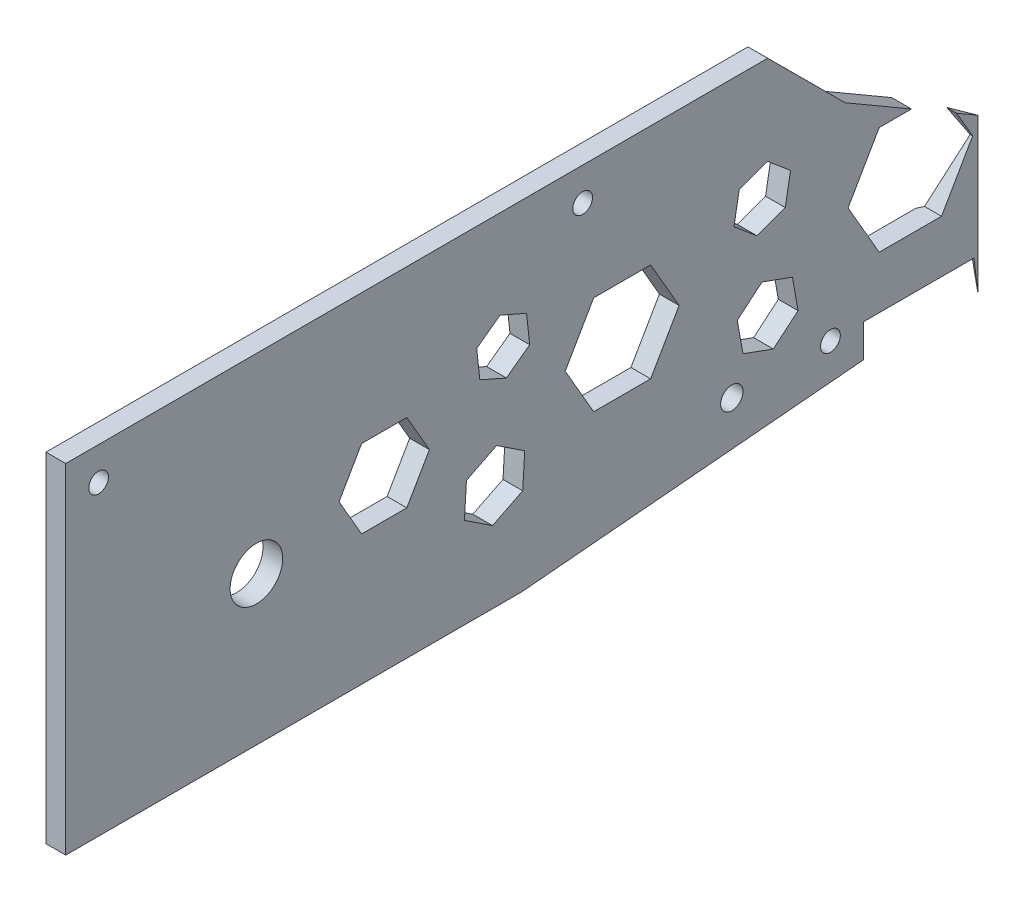
from build123d import *

# Parameters (mm, degrees)
CROQUIS1_W              = 161
CROQUIS1_H              = 51.5812
SALIENTE_EXTRUIR1_DEPTH = 3
CORTAR_EXTRUIR1_REACH   = 5
CROQUIS2_R              = 1.5
CROQUIS2_R_2            = 4
CORTAR_EXTRUIR2_REACH   = 5
CROQUIS3_R              = 1.5
CORTAR_EXTRUIR3_REACH   = 53.581
CORTAR_EXTRUIR4_DEPTH   = 3
CORTAR_EXTRUIR5_DEPTH   = 10
CORTAR_EXTRUIR6_REACH   = 5
CORTAR_EXTRUIR7_REACH   = 5
CROQUIS11_R             = 1.7
CORTAR_EXTRUIR9_DEPTH   = 10
CORTAR_EXTRUIR10_REACH  = 5


with BuildPart() as part:
    # Croquis1 → Saliente-Extruir1 (new body)
    with BuildSketch(Plane(origin=(0, 0, 0), x_dir=(0, 0, -1), z_dir=(1, 0, 0))):
        Rectangle(CROQUIS1_W, CROQUIS1_H)
    extrude(amount=SALIENTE_EXTRUIR1_DEPTH)

    # Croquis2 → Cortar-Extruir1 (cut, up to next)
    with BuildSketch(Plane(origin=(3, 0, 0), x_dir=(0, 0, -1), z_dir=(1, 0, 0)), mode=Mode.PRIVATE) as cortar_extruir1_sk1:
        with Locations((-75.5, 20.7906)):
            Circle(CROQUIS2_R)
    cortar_extruir1_tool1 = extrude(cortar_extruir1_sk1.sketch, amount=-CORTAR_EXTRUIR1_REACH, mode=Mode.PRIVATE) & part.part
    add(cortar_extruir1_tool1.solids().sort_by_distance((3, 20.7906, 75.5))[0], mode=Mode.SUBTRACT)
    # Croquis2 → Cortar-Extruir1 (cut, up to next)
    with BuildSketch(Plane(origin=(3, 0, 0), x_dir=(0, 0, -1), z_dir=(1, 0, 0)), mode=Mode.PRIVATE) as cortar_extruir1_sk2:
        with Locations((-1.88, 20.7906)):
            Circle(CROQUIS2_R)
    cortar_extruir1_tool2 = extrude(cortar_extruir1_sk2.sketch, amount=-CORTAR_EXTRUIR1_REACH, mode=Mode.PRIVATE) & part.part
    add(cortar_extruir1_tool2.solids().sort_by_distance((3, 20.7906, 1.88))[0], mode=Mode.SUBTRACT)
    # Croquis2 → Cortar-Extruir1 (cut, up to next)
    with BuildSketch(Plane(origin=(3, 0, 0), x_dir=(0, 0, -1), z_dir=(1, 0, 0)), mode=Mode.PRIVATE) as cortar_extruir1_sk3:
        with Locations((-51.5, -3.2094)):
            Circle(CROQUIS2_R_2)
    cortar_extruir1_tool3 = extrude(cortar_extruir1_sk3.sketch, amount=-CORTAR_EXTRUIR1_REACH, mode=Mode.PRIVATE) & part.part
    add(cortar_extruir1_tool3.solids().sort_by_distance((3, -3.2094, 51.5))[0], mode=Mode.SUBTRACT)

    # Croquis3 → Cortar-Extruir2 (cut, up to next)
    with BuildSketch(Plane.ZY, mode=Mode.PRIVATE) as cortar_extruir2_sk1:
        with Locations((-35.801477372, -16.2094)):
            Circle(CROQUIS3_R)
    cortar_extruir2_tool1 = extrude(cortar_extruir2_sk1.sketch, amount=-CORTAR_EXTRUIR2_REACH, mode=Mode.PRIVATE) & part.part
    add(cortar_extruir2_tool1.solids().sort_by_distance((0, -16.2094, -35.801477))[0], mode=Mode.SUBTRACT)

    # Croquis4 → Cortar-Extruir3 (cut, up to next)
    with BuildSketch(Plane(origin=(0, 25.7906, 0), x_dir=(1, 0, 0), z_dir=(0, 1, 0)), mode=Mode.PRIVATE) as cortar_extruir3_sk1:
        Polygon((0, 80.5), (3, 80.5), (3, 58.241825474), (0, 51.808304713), align=None)
    cortar_extruir3_tool1 = extrude(cortar_extruir3_sk1.sketch, amount=-CORTAR_EXTRUIR3_REACH, mode=Mode.PRIVATE) & part.part
    add(cortar_extruir3_tool1.solids().sort_by_distance((1.436864, 25.7906, -67.694835))[0], mode=Mode.SUBTRACT)

    # Croquis5 → Cortar-Extruir4 (cut)
    with BuildSketch(Plane(origin=(3, 0, 0), x_dir=(0, 0, -1), z_dir=(1, 0, 0))):
        Polygon((58.241825474, -25.7906), (58.241825474, -21.2094), (40.910881748, -21.2094), (-11.129087263, -25.7906), align=None)
    extrude(amount=-CORTAR_EXTRUIR4_DEPTH, mode=Mode.SUBTRACT)

    # Croquis6 → Cortar-Extruir5 (cut)
    with BuildSketch(Plane(origin=(3, 0, 0), x_dir=(0, 0, -1), z_dir=(1, 0, 0))):
        Polygon((58.241825474, 25.7906), (38.033287015, 25.7906), (38.033287015, 14.0406), (58.241825474, 2.2906), align=None)
    extrude(amount=-CORTAR_EXTRUIR5_DEPTH, mode=Mode.SUBTRACT)

    # Croquis7 → Cortar-Extruir6 (cut, up to next)
    with BuildSketch(Plane(origin=(3, 0, 0), x_dir=(0, 0, -1), z_dir=(1, 0, 0)), mode=Mode.PRIVATE) as cortar_extruir6_sk1:
        Polygon((38.033287015, 25.7906), (38.033287015, 14.0406), (26.25345467, 25.7906), align=None)
    cortar_extruir6_tool1 = extrude(cortar_extruir6_sk1.sketch, amount=-CORTAR_EXTRUIR6_REACH, mode=Mode.PRIVATE) & part.part
    add(cortar_extruir6_tool1.solids().sort_by_distance((3, 21.873933, -34.106676))[0], mode=Mode.SUBTRACT)

    # Croquis8 → Cortar-Extruir7 (cut, up to next)
    with BuildSketch(Plane(origin=(3, 0, 0), x_dir=(0, 0, -1), z_dir=(1, 0, 0)), mode=Mode.PRIVATE) as cortar_extruir7_sk1:
        Polygon((-38.933678241, -0.034975248), (-35.497792077, -5.986104652), (-28.626019751, -5.986104652), (-25.190133587, -0.034975248), (-28.626019751, 5.916154156), (-35.497792077, 5.916154156), align=None)
    cortar_extruir7_tool1 = extrude(cortar_extruir7_sk1.sketch, amount=-CORTAR_EXTRUIR7_REACH, mode=Mode.PRIVATE) & part.part
    add(cortar_extruir7_tool1.solids().sort_by_distance((3, -0.034975, 32.061906))[0], mode=Mode.SUBTRACT)
    # Croquis8 → Cortar-Extruir7 (cut, up to next)
    with BuildSketch(Plane(origin=(3, 0, 0), x_dir=(0, 0, -1), z_dir=(1, 0, 0)), mode=Mode.PRIVATE) as cortar_extruir7_sk2:
        Polygon((12.785187373, -0.034975248), (8.455060354, 7.465024752), (-0.205193684, 7.465024752), (-4.535320703, -0.034975248), (-0.205193684, -7.534975248), (8.455060354, -7.534975248), align=None)
    cortar_extruir7_tool2 = extrude(cortar_extruir7_sk2.sketch, amount=-CORTAR_EXTRUIR7_REACH, mode=Mode.PRIVATE) & part.part
    add(cortar_extruir7_tool2.solids().sort_by_distance((3, -0.034975, -4.124933))[0], mode=Mode.SUBTRACT)
    # Croquis8 → Cortar-Extruir7 (cut, up to next)
    with BuildSketch(Plane(origin=(3, 0, 0), x_dir=(0, 0, -1), z_dir=(1, 0, 0)), mode=Mode.PRIVATE) as cortar_extruir7_sk3:
        Polygon((29.729088218, 9.284175003), (26.224654714, 12.224743864), (21.925830627, 10.660099854), (21.131440044, 6.154886983), (24.635873548, 3.214318123), (28.934697635, 4.778962133), align=None)
    cortar_extruir7_tool3 = extrude(cortar_extruir7_sk3.sketch, amount=-CORTAR_EXTRUIR7_REACH, mode=Mode.PRIVATE) & part.part
    add(cortar_extruir7_tool3.solids().sort_by_distance((3, 7.719531, -25.430264))[0], mode=Mode.SUBTRACT)
    # Croquis8 → Cortar-Extruir7 (cut, up to next)
    with BuildSketch(Plane(origin=(3, 0, 0), x_dir=(0, 0, -1), z_dir=(1, 0, 0)), mode=Mode.PRIVATE) as cortar_extruir7_sk4:
        Polygon((-19.863794393, -12.020805521), (-15.586299257, -14.846787524), (-11.000179483, -12.555359073), (-10.691554846, -7.437948619), (-14.969049982, -4.611966616), (-19.555169756, -6.903395067), align=None)
    cortar_extruir7_tool4 = extrude(cortar_extruir7_sk4.sketch, amount=-CORTAR_EXTRUIR7_REACH, mode=Mode.PRIVATE) & part.part
    add(cortar_extruir7_tool4.solids().sort_by_distance((3, -9.729377, 15.277675))[0], mode=Mode.SUBTRACT)
    # Croquis8 → Cortar-Extruir7 (cut, up to next)
    with BuildSketch(Plane(origin=(3, 0, 0), x_dir=(0, 0, -1), z_dir=(1, 0, 0)), mode=Mode.PRIVATE) as cortar_extruir7_sk5:
        Polygon((-17.998312172, 9.702211727), (-17.519435903, 5.325448954), (-13.48961002, 3.551786582), (-9.938660407, 6.154886983), (-10.417536677, 10.531649757), (-14.447362559, 12.305312128), align=None)
    cortar_extruir7_tool5 = extrude(cortar_extruir7_sk5.sketch, amount=-CORTAR_EXTRUIR7_REACH, mode=Mode.PRIVATE) & part.part
    add(cortar_extruir7_tool5.solids().sort_by_distance((3, 7.928549, 13.968486))[0], mode=Mode.SUBTRACT)
    # Croquis8 → Cortar-Extruir7 (cut, up to next)
    with BuildSketch(Plane(origin=(3, 0, 0), x_dir=(0, 0, -1), z_dir=(1, 0, 0)), mode=Mode.PRIVATE) as cortar_extruir7_sk6:
        Polygon((30.877634676, -9.772162222), (30.023928106, -4.930551671), (25.404117088, -3.249077972), (21.63801264, -6.409214825), (22.491719211, -11.250825377), (27.111530229, -12.932299075), align=None)
    cortar_extruir7_tool6 = extrude(cortar_extruir7_sk6.sketch, amount=-CORTAR_EXTRUIR7_REACH, mode=Mode.PRIVATE) & part.part
    add(cortar_extruir7_tool6.solids().sort_by_distance((3, -8.090689, -26.257824))[0], mode=Mode.SUBTRACT)
    # Croquis8 → Cortar-Extruir7 (cut, up to next)
    with BuildSketch(Plane(origin=(3, 0, 0), x_dir=(0, 0, -1), z_dir=(1, 0, 0)), mode=Mode.PRIVATE) as cortar_extruir7_sk7:
        Polygon((57.427116401, -0.034975248), (52.689414159, 8.170965745), (43.214009677, 8.170965745), (38.476307436, -0.034975248), (43.214009677, -8.240916241), (52.689414159, -8.240916241), align=None)
    cortar_extruir7_tool7 = extrude(cortar_extruir7_sk7.sketch, amount=-CORTAR_EXTRUIR7_REACH, mode=Mode.PRIVATE) & part.part
    add(cortar_extruir7_tool7.solids().sort_by_distance((3, -0.034975, -47.951712))[0], mode=Mode.SUBTRACT)

    # Croquis11 → Cortar-Extruir9 (cut)
    with BuildSketch(Plane.ZY):
        with Locations((-20.801477372, -16.2094)):
            Circle(CROQUIS11_R)
    extrude(amount=-CORTAR_EXTRUIR9_DEPTH, mode=Mode.SUBTRACT)

    # Croquis12 → Cortar-Extruir10 (cut, up to next)
    with BuildSketch(Plane(origin=(3, 0, 0), x_dir=(0, 0, -1), z_dir=(1, 0, 0)), mode=Mode.PRIVATE) as cortar_extruir10_sk1:
        Polygon((58.241825474, -21.2094), (57.627058446, -16.2094), (40.81163491, -16.2094), (40.81163491, -21.218136931), (40.910881748, -21.2094), align=None)
    cortar_extruir10_tool1 = extrude(cortar_extruir10_sk1.sketch, amount=-CORTAR_EXTRUIR10_REACH, mode=Mode.PRIVATE) & part.part
    add(cortar_extruir10_tool1.solids().sort_by_distance((3, -18.724372, -49.373915))[0], mode=Mode.SUBTRACT)


solid = part.part
